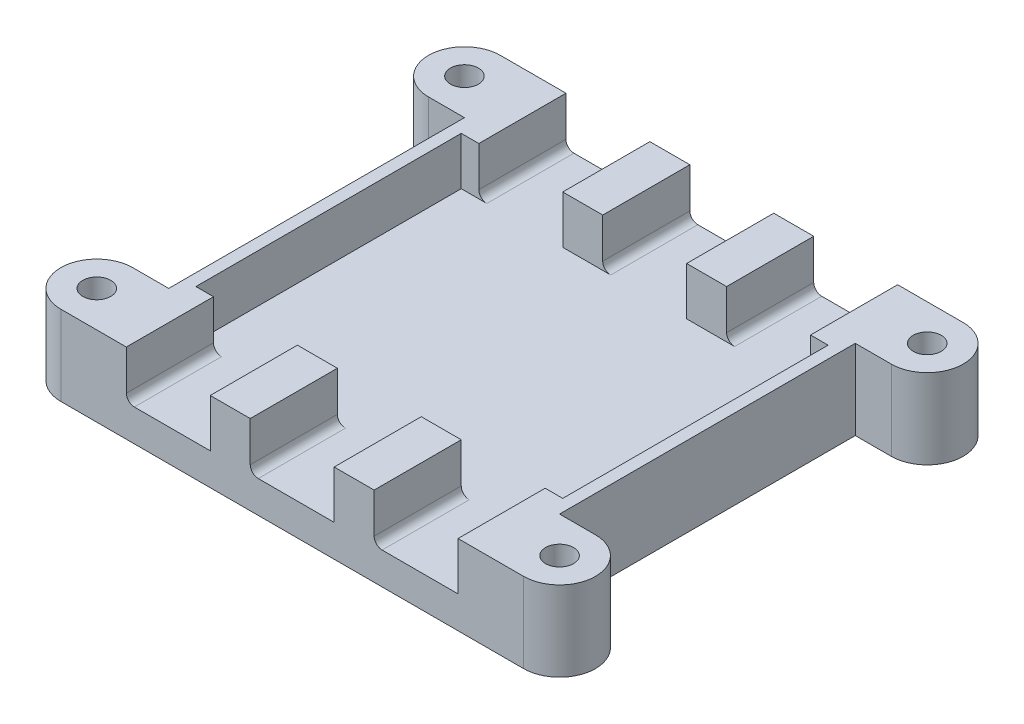
from build123d import *

# Parameters (mm, degrees)
SKETCH1_W           = 48.9
SKETCH1_H           = 55
SKETCH1_W_2         = 45.9
SKETCH1_H_2         = 9.4
SKETCH1_H_3         = 33.2
BOSS_EXTRUDE1_DEPTH = 4
SKETCH2_W           = 1.5
SKETCH2_H           = 33.2
SKETCH2_W_2         = 5
SKETCH2_H_2         = 1.5
SKETCH2_H_3         = 9.4
SKETCH2_W_3         = 2.2
BOSS_EXTRUDE2_DEPTH = 6
SKETCH4_R           = 4.5
SKETCH4_R_2         = 1.75
BOSS_EXTRUDE3_DEPTH = 10
FILLET1_R           = 1
CUT_EXTRUDE1_DEPTH  = 2.75


with BuildPart() as part:
    # Sketch1 → Boss-Extrude1 (new body)
    with BuildSketch(Plane(origin=(0, 0, 0), x_dir=(1, 0, 0), z_dir=(0, 1, 0))):
        Rectangle(SKETCH1_W, SKETCH1_H)
        Polygon((22.95, 26), (22.95, 16.6), (22.95, -16.6), (22.95, -26), (-22.95, -26), (-22.95, -16.6), (-22.95, 16.6), (-22.95, 26), align=None, mode=Mode.SUBTRACT)
        with Locations((0, 21.3)):
            Rectangle(SKETCH1_W_2, SKETCH1_H_2)
        Rectangle(SKETCH1_W_2, SKETCH1_H_3)
        with Locations((0, -21.3)):
            Rectangle(SKETCH1_W_2, SKETCH1_H_2)
    extrude(amount=BOSS_EXTRUDE1_DEPTH)

    # Sketch2 → Boss-Extrude2 (add)
    with BuildSketch(Plane(origin=(0, 4, 0), x_dir=(1, 0, 0), z_dir=(0, 1, 0))):
        Polygon((-24.45, 16.6), (-22.95, 16.6), (-22.95, 26), (-20.75, 26), (-20.75, 27.5), (-24.45, 27.5), align=None)
        with Locations((-23.7, 0)):
            Rectangle(SKETCH2_W, SKETCH2_H)
        Polygon((-22.95, -26), (-22.95, -16.6), (-24.45, -16.6), (-24.45, -27.5), (-20.75, -27.5), (-20.75, -26), align=None)
        with Locations((-7.75, -26.75)):
            Rectangle(SKETCH2_W_2, SKETCH2_H_2)
        with Locations((7.75, -26.75)):
            Rectangle(SKETCH2_W_2, SKETCH2_H_2)
        Polygon((24.45, -16.6), (22.95, -16.6), (22.95, -26), (20.75, -26), (20.75, -27.5), (24.45, -27.5), align=None)
        with Locations((23.7, 0)):
            Rectangle(SKETCH2_W, SKETCH2_H)
        Polygon((22.95, 26), (22.95, 16.6), (24.45, 16.6), (24.45, 27.5), (20.75, 27.5), (20.75, 26), align=None)
        with Locations((7.75, 26.75)):
            Rectangle(SKETCH2_W_2, SKETCH2_H_2)
        with Locations((-7.75, 26.75)):
            Rectangle(SKETCH2_W_2, SKETCH2_H_2)
        with Locations((-7.75, 21.3)):
            Rectangle(SKETCH2_W_2, SKETCH2_H_3)
        with Locations((7.75, 21.3)):
            Rectangle(SKETCH2_W_2, SKETCH2_H_3)
        with Locations((7.75, -21.3)):
            Rectangle(SKETCH2_W_2, SKETCH2_H_3)
        with Locations((-7.75, -21.3)):
            Rectangle(SKETCH2_W_2, SKETCH2_H_3)
        with Locations((-21.85, 21.3)):
            Rectangle(SKETCH2_W_3, SKETCH2_H_3)
        with Locations((21.85, 21.3)):
            Rectangle(SKETCH2_W_3, SKETCH2_H_3)
        with Locations((21.85, -21.3)):
            Rectangle(SKETCH2_W_3, SKETCH2_H_3)
        with Locations((-21.85, -21.3)):
            Rectangle(SKETCH2_W_3, SKETCH2_H_3)
    extrude(amount=BOSS_EXTRUDE2_DEPTH)

    # Sketch4 → Boss-Extrude3 (add)
    with BuildSketch(Plane.XZ):
        with BuildLine():
            Line((-24.45, 27.5), (-28.95, 27.5))
            ThreePointArc((-28.95, 27.5), (-25.768019485, 26.181980515), (-24.45, 23))
            Line((-24.45, 23), (-24.45, 27.5))
        make_face()
        with BuildLine():
            Line((-24.45, 18.5), (-24.45, 23))
            ThreePointArc((-24.45, 23), (-25.768019485, 19.818019485), (-28.95, 18.5))
            Line((-28.95, 18.5), (-24.45, 18.5))
        make_face()
        with Locations((-28.95, 23)):
            Circle(SKETCH4_R)
        with Locations((-28.95, 23)):
            Circle(SKETCH4_R_2, mode=Mode.SUBTRACT)
        with BuildLine():
            ThreePointArc((24.45, 22.999999999), (25.768019484, 26.181980515), (28.95, 27.5))
            Line((28.95, 27.5), (24.45, 27.5))
            Line((24.45, 27.5), (24.45, 22.999999999))
        make_face()
        with Locations((28.95, 23)):
            Circle(SKETCH4_R)
        with Locations((28.95, 23)):
            Circle(SKETCH4_R_2, mode=Mode.SUBTRACT)
        with BuildLine():
            ThreePointArc((28.95, 18.5), (25.768019485, 19.818019484), (24.45, 22.999999999))
            Line((24.45, 22.999999999), (24.45, 18.5))
            Line((24.45, 18.5), (28.95, 18.5))
        make_face()
        with Locations((28.95, -23)):
            Circle(SKETCH4_R)
        with Locations((28.95, -23)):
            Circle(SKETCH4_R_2, mode=Mode.SUBTRACT)
        with BuildLine():
            ThreePointArc((28.95, -27.5), (25.768019485, -26.181980515), (24.45, -23))
            Line((24.45, -23), (24.45, -27.5))
            Line((24.45, -27.5), (28.95, -27.5))
        make_face()
        with BuildLine():
            Line((28.95, -18.5), (24.45, -18.5))
            Line((24.45, -18.5), (24.45, -23))
            ThreePointArc((24.45, -23), (25.768019485, -19.818019485), (28.95, -18.5))
        make_face()
        with BuildLine():
            Line((-24.45, -27.5), (-24.45, -23))
            ThreePointArc((-24.45, -23), (-25.768019485, -26.181980515), (-28.95, -27.5))
            Line((-28.95, -27.5), (-24.45, -27.5))
        make_face()
        with BuildLine():
            Line((-24.45, -23), (-24.45, -18.5))
            Line((-24.45, -18.5), (-28.95, -18.5))
            ThreePointArc((-28.95, -18.5), (-25.768019485, -19.818019485), (-24.45, -23))
        make_face()
        with Locations((-28.95, -23)):
            Circle(SKETCH4_R)
        with Locations((-28.95, -23)):
            Circle(SKETCH4_R_2, mode=Mode.SUBTRACT)
    extrude(amount=-BOSS_EXTRUDE3_DEPTH)

    # Fillet1
    fillet1_edges = [part.edges().sort_by_distance(p)[0] for p in [
        (-5.25, 4, -22.05),
        (10.25, 4, -22.05),
        (10.25, 4, 22.05),
        (-5.25, 4, 22.05),
        (-20.75, 4, -22.05),
        (-20.75, 4, 22.05),
    ]]
    fillet(fillet1_edges, radius=FILLET1_R)

    # Sketch5 → Cut-Extrude1 (cut)
    with BuildSketch(Plane.XZ):
        Polygon((-28.95, 19.709103466), (-26.1, 21.354551733), (-26.1, 24.645448267), (-28.95, 26.290896534), (-31.8, 24.645448267), (-31.8, 21.354551733), align=None)
        Polygon((31.8, 21.354551733), (28.95, 19.709103466), (26.1, 21.354551733), (26.1, 24.645448267), (28.95, 26.290896534), (31.8, 24.645448267), align=None)
        Polygon((31.8, -21.354551733), (28.95, -19.709103466), (26.1, -21.354551733), (26.1, -24.645448267), (28.95, -26.290896534), (31.8, -24.645448267), align=None)
        Polygon((-31.8, -21.354551733), (-28.95, -19.709103466), (-26.1, -21.354551733), (-26.1, -24.645448267), (-28.95, -26.290896534), (-31.8, -24.645448267), align=None)
    extrude(amount=-CUT_EXTRUDE1_DEPTH, mode=Mode.SUBTRACT)


solid = part.part
